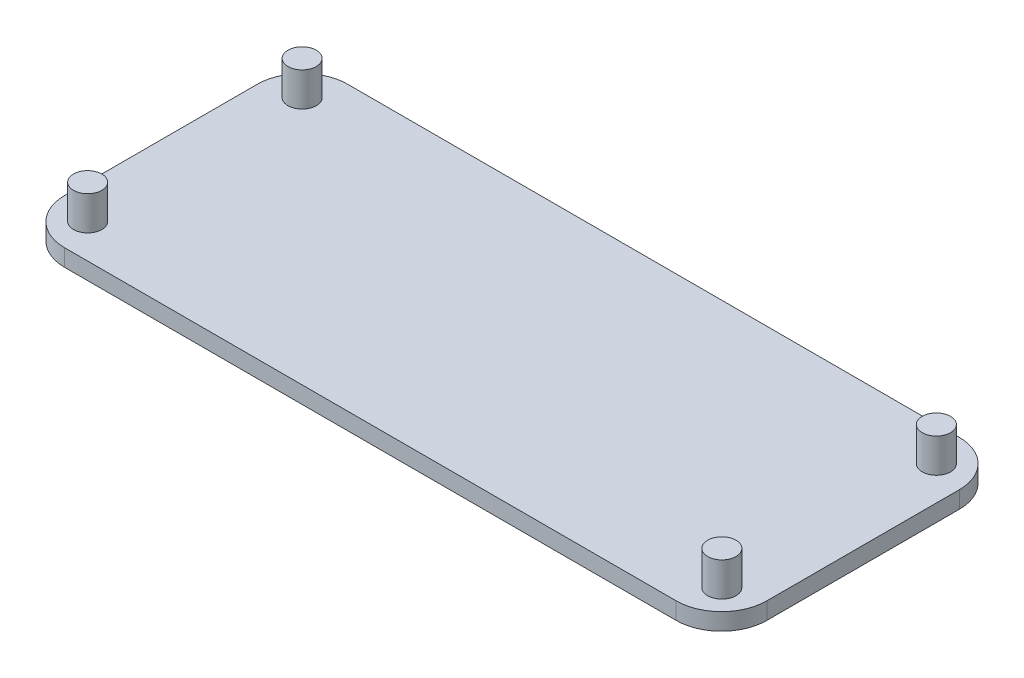
from build123d import *

# Parameters (mm, degrees)
CROQUIS1_W              = 62
CROQUIS1_H              = 25
SALIENTE_EXTRUIR1_DEPTH = 1.5
REDONDEO1_R             = 4
CROQUIS2_R              = 1.25
SALIENTE_EXTRUIR2_DEPTH = 3


with BuildPart() as part:
    # Croquis1 → Saliente-Extruir1 (new body)
    with BuildSketch(Plane(origin=(0, 0, 0), x_dir=(1, 0, 0), z_dir=(0, 1, 0))):
        Rectangle(CROQUIS1_W, CROQUIS1_H)
    extrude(amount=SALIENTE_EXTRUIR1_DEPTH)

    # Redondeo1
    redondeo1_edges = [part.edges().sort_by_distance(p)[0] for p in [
        (31, 0.75, 12.5),
        (-31, 0.75, 12.5),
        (-31, 0.75, -12.5),
        (31, 0.75, -12.5),
    ]]
    fillet(redondeo1_edges, radius=REDONDEO1_R)

    # Croquis2 → Saliente-Extruir2 (add)
    with BuildSketch(Plane(origin=(0, 1.5, 0), x_dir=(1, 0, 0), z_dir=(0, 1, 0))):
        with Locations((-28, 9.47)):
            Circle(CROQUIS2_R)
        with Locations((28, 9.47)):
            Circle(CROQUIS2_R)
        with Locations((28, -9.47)):
            Circle(CROQUIS2_R)
        with Locations((-28, -9.47)):
            Circle(CROQUIS2_R)
    extrude(amount=SALIENTE_EXTRUIR2_DEPTH)


solid = part.part
